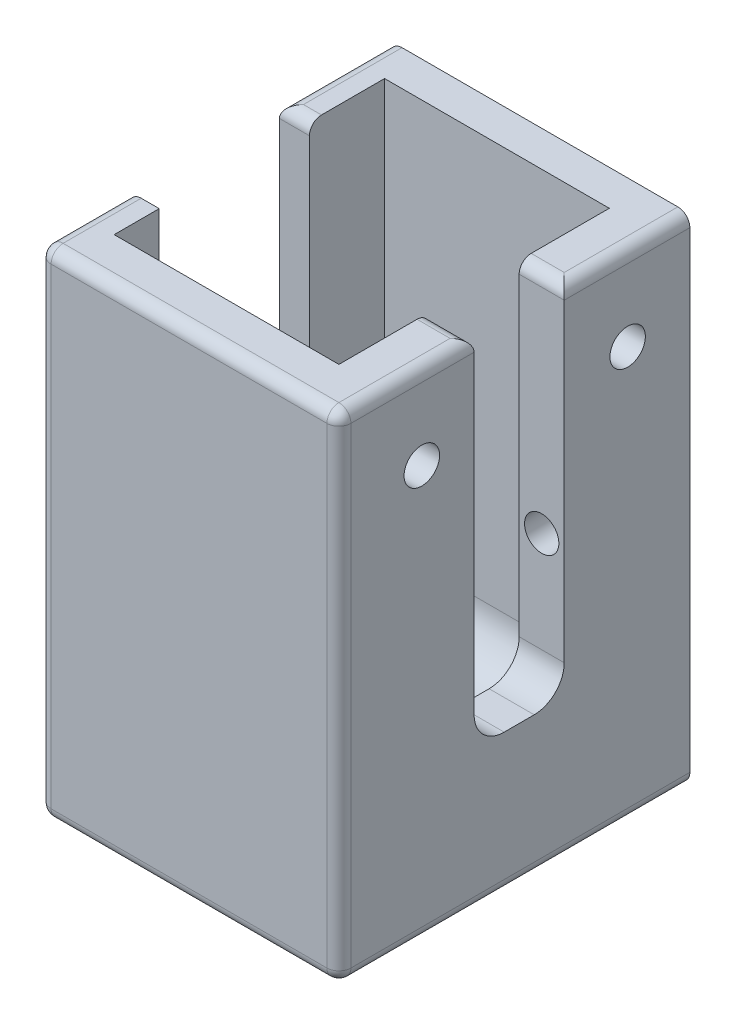
from build123d import *

# Parameters (mm, degrees)
BOSS_EXTRUDE2_DEPTH = 38.1
SKETCH1_W           = 25.35
SKETCH1_H           = 29.67
BOSS_EXTRUDE3_DEPTH = 3.81
SKETCH3_W           = 3
SKETCH3_H           = 7.62
CUT_EXTRUDE1_DEPTH  = 4.81
SKETCH4_W           = 7.62
SKETCH4_H           = 30.1
CUT_EXTRUDE2_DEPTH  = 4.81
SKETCH5_R           = 1.5
CUT_EXTRUDE3_DEPTH  = 4.81
SKETCH6_R           = 1.45
CUT_EXTRUDE4_DEPTH  = 24.844
FILLET1_R           = 4
FILLET4_R           = 2.54
FILLET2_R           = 1.016
FILLET3_R           = 1.27
FILLET5_R           = 1.016
CUT_EXTRUDE5_DEPTH  = 1.27
CUT_EXTRUDE6_DEPTH  = 1.27


with BuildPart() as part:
    # Sketch2 → Boss-Extrude2 (new body)
    with BuildSketch(Plane(origin=(0, 0, 0), x_dir=(1, 0, 0), z_dir=(0, 1, 0))):
        Polygon((-9.5, -11.43), (9.5, -11.43), (9.5, -5.08), (12.04, -5.08), (12.04, -14.43), (-13.31, -14.43), (-13.31, 15.24), (12.04, 15.24), (12.04, 7.62), (9.5, 7.62), (9.5, 11.43), (-9.5, 11.43), align=None)
    extrude(amount=BOSS_EXTRUDE2_DEPTH)

    # Sketch1 → Boss-Extrude3 (add)
    with BuildSketch(Plane(origin=(0, 0, 0), x_dir=(1, 0, 0), z_dir=(0, 1, 0))):
        with Locations((-0.635, 0.405)):
            Rectangle(SKETCH1_W, SKETCH1_H)
    extrude(amount=-BOSS_EXTRUDE3_DEPTH)

    # Sketch3 → Cut-Extrude1 (cut, through all)
    with BuildSketch(Plane(origin=(0, 0, 0), x_dir=(1, 0, 0), z_dir=(0, 1, 0))):
        with Locations((-0.38, 0)):
            Rectangle(SKETCH3_W, SKETCH3_H)
    extrude(amount=-CUT_EXTRUDE1_DEPTH, mode=Mode.SUBTRACT)

    # Sketch4 → Cut-Extrude2 (cut, through all)
    with BuildSketch(Plane(origin=(-9.5, 0, 0), x_dir=(0, 0, -1), z_dir=(1, 0, 0))):
        with Locations((0, 23.05)):
            Rectangle(SKETCH4_W, SKETCH4_H)
    extrude(amount=-CUT_EXTRUDE2_DEPTH, mode=Mode.SUBTRACT)

    # Sketch5 → Cut-Extrude3 (cut, through all)
    with BuildSketch(Plane(origin=(-9.5, 0, 0), x_dir=(0, 0, -1), z_dir=(1, 0, 0))):
        with Locations((-9.1700096, 31)):
            Circle(SKETCH5_R)
        with Locations((8.2299904, 31)):
            Circle(SKETCH5_R)
    extrude(amount=-CUT_EXTRUDE3_DEPTH, mode=Mode.SUBTRACT)

    # Sketch6 → Cut-Extrude4 (cut)
    with BuildSketch(Plane.XY.offset(14.43)):
        with Locations((-11.405, 19.05)):
            Circle(SKETCH6_R)
        with Locations((-3.81, -1.905)):
            Circle(SKETCH6_R)
    extrude(amount=-CUT_EXTRUDE4_DEPTH, mode=Mode.SUBTRACT)

    # Fillet1
    fillet1_edges = [part.edges().sort_by_distance(p)[0] for p in [
        (0, 0, -11.43),
        (0, 0, 11.43),
    ]]
    fillet(fillet1_edges, radius=FILLET1_R)


with BuildPart() as body_2:
    # Mirror1: mirrored copy
    add(part.part.mirror(Plane.XY))

    # Fillet4
    fillet4_edges = [body_2.edges().sort_by_distance(p)[0] for p in [
        (-11.405, 8, -3.81),
        (-11.405, 8, 3.81),
    ]]
    fillet(fillet4_edges, radius=FILLET4_R)

    # Fillet2
    fillet2_edges = [body_2.edges().sort_by_distance(p)[0] for p in [
        (-13.31, 17.145, 15.24),
        (12.04, 17.145, 15.24),
        (12.04, -3.81, 0.405),
        (-13.31, -3.81, 0.405),
        (-0.635, -3.81, 15.24),
        (12.04, 38.1, 11.43),
        (-0.635, 38.1, 15.24),
        (-13.31, 38.1, 9.525),
        (-13.31, 38.1, -9.12),
        (-11.405, 38.1, -3.81),
        (-11.405, 38.1, 3.81),
    ]]
    fillet(fillet2_edges, radius=FILLET2_R)

    # Fillet3
    fillet3_edges = [body_2.edges().sort_by_distance(p)[0] for p in [
        (-1.88, 0, 0),
        (-0.38, 0, -3.81),
        (1.12, 0, 0),
        (-0.38, 0, 3.81),
    ]]
    fillet(fillet3_edges, radius=FILLET3_R)

    # Fillet5
    fillet5_edges = [body_2.edges().sort_by_distance(p)[0] for p in [
        (12.04, 38.1, -9.755),
        (10.77, 38.1, -5.08),
    ]]
    fillet(fillet5_edges, radius=FILLET5_R)


with BuildPart() as body_2_2:
    # Mirror3: mirrored copy
    add(body_2.part.mirror(Plane.ZY.offset(15.85)))

    # Sketch8 → Cut-Extrude6 (cut)
    with BuildSketch(Plane(origin=(0, 0, 0), x_dir=(1, 0, 0), z_dir=(0, 1, 0))):
        Polygon((-35.125709402, -4.085355142), (-35.125709402, -4.750205569), (-37.310217949, -4.750205569), (-37.310217949, -5.699991894), (-37.975068376, -5.699991894), (-37.975068376, -4.750205569), (-42.724, -4.750205569), (-42.724, -4.085355142), (-37.975068376, -4.085355142), (-37.975068376, -3.135568817), (-37.310217949, -3.135568817), (-37.310217949, -4.085355142), align=None)
        with BuildLine():
            Line((-35.315666667, 2.658127764), (-35.315666667, 1.175570673))
            add(Edge.make_bspline(
                [(-35.315666667, 1.175570673), (-35.31599599, 1.076635284), (-35.316628328, 0.886668378), (-35.320154193, 0.614521623), (-35.330259913, 0.367237601), (-35.338956414, 0.144945608), (-35.354814357, -0.052350279), (-35.36997106, -0.225255044), (-35.389811975, -0.372972337), (-35.408238454, -0.462392723), (-35.416581464, -0.502879848)],
                knots=[0, 0, 0, 0, 0.000296812, 0.000569912, 0.000816423, 0.001039272, 0.001237207, 0.001410128, 0.001559979, 0.001683965, 0.001683965, 0.001683965, 0.001683965], degree=3))
            add(Edge.make_bspline(
                [(-35.416581464, -0.502879848), (-35.429971598, -0.557081491), (-35.456466218, -0.664328507), (-35.512494413, -0.81872563), (-35.577224639, -0.965915382), (-35.653842803, -1.105345402), (-35.741012521, -1.237028627), (-35.839243094, -1.360767889), (-35.949034771, -1.475855736), (-36.067583937, -1.583177714), (-36.195924968, -1.680461633), (-36.332188282, -1.764648136), (-36.475521634, -1.836736616), (-36.626424162, -1.894287018), (-36.783620234, -1.940584552), (-36.948482467, -1.973239748), (-37.120273858, -1.992820602), (-37.237448007, -1.99481431), (-37.296861579, -1.995825227)],
                knots=[0, 0, 0, 0, 0.000167388, 0.000331205, 0.000491982, 0.000649388, 0.000807854, 0.000965226, 0.001122688, 0.00128451, 0.00144449, 0.001605103, 0.001764387, 0.001925062, 0.002088959, 0.002255437, 0.002428663, 0.002606847, 0.002606847, 0.002606847, 0.002606847], degree=3))
            add(Edge.make_bspline(
                [(-37.296861579, -1.995825227), (-37.395572664, -1.992715929), (-37.588183557, -1.986648882), (-37.867710836, -1.930079619), (-38.128467354, -1.83742344), (-38.370090229, -1.709723959), (-38.587996871, -1.547178937), (-38.778744039, -1.351836783), (-38.939838712, -1.124695094), (-39.050363857, -0.91224832), (-39.121480472, -0.724494941), (-39.171769577, -0.569470973), (-39.209969011, -0.400237622), (-39.244686959, -0.219222799), (-39.271179543, -0.025028326), (-39.289994312, 0.181954737), (-39.302092352, 0.402244067), (-39.303859928, 0.553246562), (-39.304769231, 0.630927577)],
                knots=[0, 0, 0, 0, 0.000295861, 0.000577301, 0.000851427, 0.001123618, 0.001394011, 0.001663719, 0.001939227, 0.00222663, 0.002379313, 0.002541237, 0.002715098, 0.00289934, 0.003094106, 0.003302766, 0.003522724, 0.003755761, 0.003755761, 0.003755761, 0.003755761], degree=3))
            Line((-39.304769231, 0.630927577), (-42.724, -2.09080386))
            Line((-42.724, -2.09080386), (-42.724, -1.268645072))
            Line((-42.724, -1.268645072), (-39.304769231, 1.453086364))
            Line((-39.304769231, 1.453086364), (-39.304769231, 1.993277337))
            Line((-39.304769231, 1.993277337), (-42.724, 1.993277337))
            Line((-42.724, 1.993277337), (-42.724, 2.658127764))
            Line((-42.724, 2.658127764), (-35.315666667, 2.658127764))
        make_face()
        with BuildLine():
            Line((-36.075495726, 1.993277337), (-38.544940171, 1.993277337))
            Line((-38.544940171, 1.993277337), (-38.555328459, 0.636863742))
            add(Edge.make_bspline(
                [(-38.555328459, 0.636863742), (-38.555356476, 0.573532993), (-38.555410782, 0.450779964), (-38.546957292, 0.27319022), (-38.537340592, 0.107835996), (-38.522631175, -0.044650303), (-38.503674054, -0.184336572), (-38.479961405, -0.31115373), (-38.452333452, -0.425306376), (-38.409577922, -0.55844757), (-38.341800903, -0.707074645), (-38.243358644, -0.86880077), (-38.118738571, -1.006056387), (-37.978502281, -1.124397331), (-37.821144229, -1.215549999), (-37.653648946, -1.281893149), (-37.477462473, -1.323527172), (-37.356448737, -1.328476869), (-37.295377537, -1.3309748)],
                knots=[0, 0, 0, 0, 0.000189963, 0.000368203, 0.000533258, 0.000686833, 0.000827661, 0.00095602, 0.001073718, 0.001179783, 0.001375069, 0.001562422, 0.001745315, 0.001928677, 0.002110918, 0.002288116, 0.002467759, 0.002650784, 0.002650784, 0.002650784, 0.002650784], degree=3))
            add(Edge.make_bspline(
                [(-37.295377537, -1.3309748), (-37.235784101, -1.328469191), (-37.117691657, -1.323503988), (-36.945281883, -1.281812481), (-36.781395026, -1.214486794), (-36.629154879, -1.120080599), (-36.489810496, -1.006005192), (-36.372231955, -0.870523684), (-36.27376678, -0.720459089), (-36.211303642, -0.580102451), (-36.172931546, -0.454736188), (-36.145962748, -0.345871562), (-36.124112719, -0.222396299), (-36.107124734, -0.084606312), (-36.091837488, 0.067249114), (-36.081925643, 0.233585788), (-36.075934923, 0.414211629), (-36.075645532, 0.539406498), (-36.075495726, 0.604214837)],
                knots=[0, 0, 0, 0, 0.000178585, 0.00035389, 0.000528894, 0.000708076, 0.000889348, 0.001067068, 0.001244067, 0.001426091, 0.001525599, 0.001637179, 0.00176235, 0.00190151, 0.002053608, 0.002220145, 0.002401295, 0.00259571, 0.00259571, 0.00259571, 0.00259571], degree=3))
            Line((-36.075495726, 0.604214837), (-36.075495726, 1.993277337))
        make_face(mode=Mode.SUBTRACT)
    extrude(amount=-CUT_EXTRUDE6_DEPTH, mode=Mode.SUBTRACT)


with BuildPart() as body_2_1:
    add(body_2.part)

    # Sketch7 → Cut-Extrude5 (cut)
    with BuildSketch(Plane(origin=(0, 0, 0), x_dir=(1, 0, 0), z_dir=(0, 1, 0))):
        Polygon((4.129986879, -2.992887734), (4.129986879, -2.328037307), (10.778491153, -2.328037307), (10.778491153, 0.521321667), (11.538320213, 0.521321667), (11.538320213, -2.992887734), align=None)
        Polygon((3.940029614, 2.230937052), (3.940029614, 2.895787479), (6.124538161, 2.895787479), (6.124538161, 3.845573804), (6.789388589, 3.845573804), (6.789388589, 2.895787479), (11.538320213, 2.895787479), (11.538320213, 2.230937052), (6.789388589, 2.230937052), (6.789388589, 1.281150727), (6.124538161, 1.281150727), (6.124538161, 2.230937052), align=None)
    extrude(amount=-CUT_EXTRUDE5_DEPTH, mode=Mode.SUBTRACT)


solid = body_2_2.part
